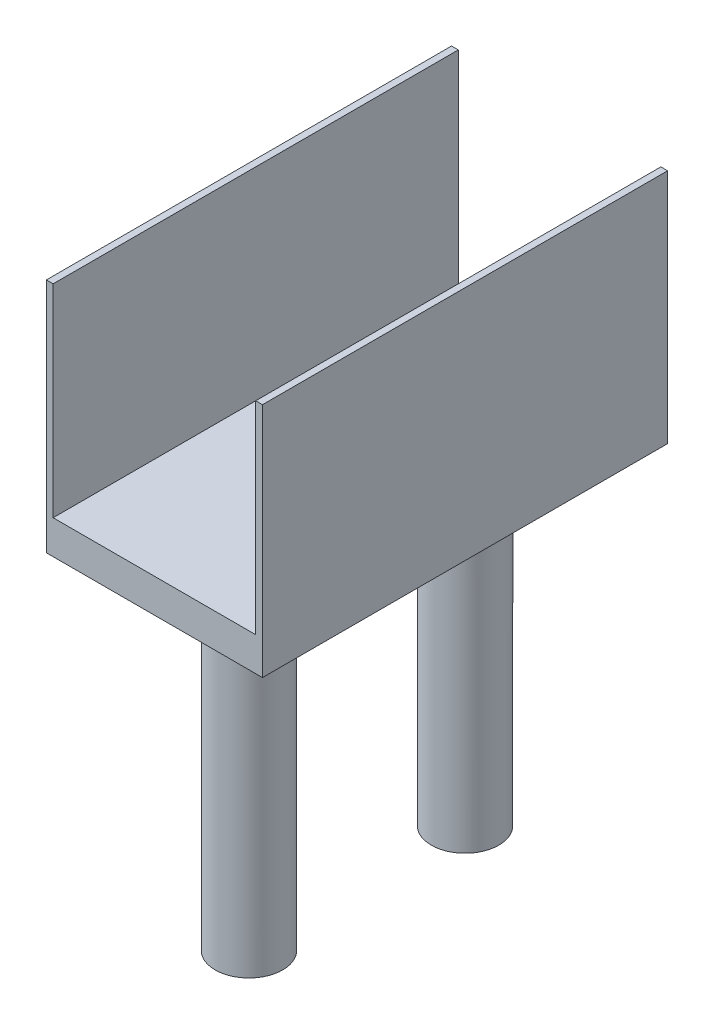
from build123d import *

# Parameters (mm, degrees)
SKETCH1_W           = 32
SKETCH1_H           = 60
BOSS_EXTRUDE1_DEPTH = 2.5
SKETCH2_R           = 5
BOSS_EXTRUDE2_DEPTH = 50
SKETCH3_W           = 1
SKETCH3_H           = 60
BOSS_EXTRUDE3_DEPTH = 30


with BuildPart() as part:
    # Sketch1 → Boss-Extrude1 (new body, symmetric)
    with BuildSketch(Plane(origin=(0, 0, 0), x_dir=(1, 0, 0), z_dir=(0, 1, 0))):
        Rectangle(SKETCH1_W, SKETCH1_H)
    extrude(amount=BOSS_EXTRUDE1_DEPTH, both=True)

    # Sketch2 → Boss-Extrude2 (add)
    with BuildSketch(Plane.XZ.offset(2.5)):
        with Locations((0, 16)):
            Circle(SKETCH2_R)
        with Locations((0, -16)):
            Circle(SKETCH2_R)
    extrude(amount=BOSS_EXTRUDE2_DEPTH)

    # Sketch3 → Boss-Extrude3 (add)
    with BuildSketch(Plane(origin=(0, 2.5, 0), x_dir=(1, 0, 0), z_dir=(0, 1, 0))):
        with Locations((-15.5, 0)):
            Rectangle(SKETCH3_W, SKETCH3_H)
        with Locations((15.5, 0)):
            Rectangle(SKETCH3_W, SKETCH3_H)
    extrude(amount=BOSS_EXTRUDE3_DEPTH)


solid = part.part
